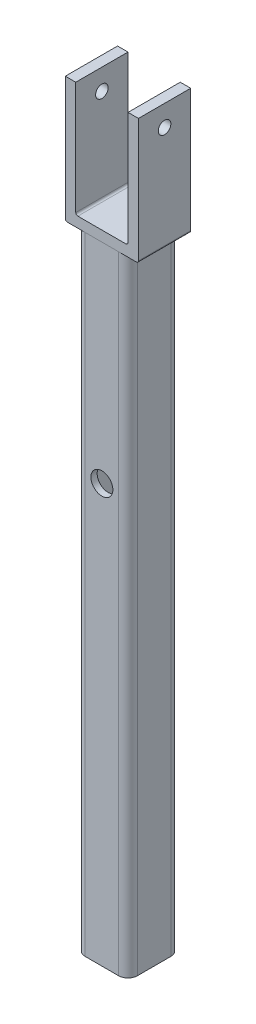
from build123d import *

# Parameters (mm, degrees)
BOSS_EXTRUDE1_DEPTH = 300
SKETCH2_R           = 7.5
CUT_EXTRUDE1_DEPTH  = 3
SKETCH3_R           = 5.25
CUT_EXTRUDE2_DEPTH  = 3
SKETCH5_W           = 35
SKETCH5_H           = 25
BOSS_EXTRUDE2_DEPTH = 60
SKETCH7_W           = 25
SKETCH7_H           = 25
CUT_EXTRUDE4_DEPTH  = 55
SKETCH8_R           = 3
CUT_EXTRUDE5_DEPTH  = 55
FILLET1_R           = 1
FILLET2_R           = 1


with BuildPart() as part:
    # Sketch1 → Boss-Extrude1 (new body)
    with BuildSketch(Plane(origin=(0, 0, 0), x_dir=(1, 0, 0), z_dir=(0, 1, 0))):
        with BuildLine():
            Line((8, 12.5), (-8, 12.5))
            ThreePointArc((-8, 12.5), (-11.181980515, 11.181980515), (-12.5, 8))
            Line((-12.5, 8), (-12.5, -8))
            ThreePointArc((-12.5, -8), (-11.181980515, -11.181980515), (-8, -12.5))
            Line((-8, -12.5), (8, -12.5))
            ThreePointArc((8, -12.5), (11.181980515, -11.181980515), (12.5, -8))
            Line((12.5, -8), (12.5, 8))
            ThreePointArc((12.5, 8), (11.181980515, 11.181980515), (8, 12.5))
        make_face()
        with BuildLine():
            Line((-6.5, 9.5), (6.5, 9.5))
            ThreePointArc((6.5, 9.5), (8.621320344, 8.621320344), (9.5, 6.5))
            Line((9.5, 6.5), (9.5, -6.5))
            ThreePointArc((9.5, -6.5), (8.621320344, -8.621320344), (6.5, -9.5))
            Line((6.5, -9.5), (-6.5, -9.5))
            ThreePointArc((-6.5, -9.5), (-8.621320344, -8.621320344), (-9.5, -6.5))
            Line((-9.5, -6.5), (-9.5, 6.5))
            ThreePointArc((-9.5, 6.5), (-8.621320344, 8.621320344), (-6.5, 9.5))
        make_face(mode=Mode.SUBTRACT)
    extrude(amount=BOSS_EXTRUDE1_DEPTH)

    # Sketch2 → Cut-Extrude1 (cut)
    with BuildSketch(Plane(origin=(0, 0, -12.5), x_dir=(-1, 0, 0), z_dir=(0, 0, -1))):
        with Locations((0, 200)):
            Circle(SKETCH2_R)
    extrude(amount=-CUT_EXTRUDE1_DEPTH, mode=Mode.SUBTRACT)

    # Sketch3 → Cut-Extrude2 (cut)
    with BuildSketch(Plane.XY.offset(12.5)):
        with Locations((0, 200)):
            Circle(SKETCH3_R)
    extrude(amount=-CUT_EXTRUDE2_DEPTH, mode=Mode.SUBTRACT)


with BuildPart() as body_2:
    # Sketch5 → Boss-Extrude2 (new body)
    with BuildSketch(Plane(origin=(0, 300, 0), x_dir=(1, 0, 0), z_dir=(0, 1, 0))):
        Rectangle(SKETCH5_W, SKETCH5_H)
    extrude(amount=BOSS_EXTRUDE2_DEPTH)

    # Sketch7 → Cut-Extrude4 (cut)
    with BuildSketch(Plane(origin=(0, 360, 0), x_dir=(1, 0, 0), z_dir=(0, 1, 0))):
        Rectangle(SKETCH7_W, SKETCH7_H)
    extrude(amount=-CUT_EXTRUDE4_DEPTH, mode=Mode.SUBTRACT)

    # Sketch8 → Cut-Extrude5 (cut)
    with BuildSketch(Plane.ZY.offset(17.5)):
        with Locations((0, 350)):
            Circle(SKETCH8_R)
    extrude(amount=-CUT_EXTRUDE5_DEPTH, mode=Mode.SUBTRACT)

    # Fillet1
    fillet1_edges = [body_2.edges().sort_by_distance(p)[0] for p in [
        (-12.5, 305, 0),
        (12.5, 305, 0),
    ]]
    fillet(fillet1_edges, radius=FILLET1_R)

    # Fillet2
    fillet2_edges = [body_2.edges().sort_by_distance(p)[0] for p in [
        (17.5, 300, 0),
        (-17.5, 300, 0),
    ]]
    fillet(fillet2_edges, radius=FILLET2_R)


solid = Compound([part.part, body_2.part])
